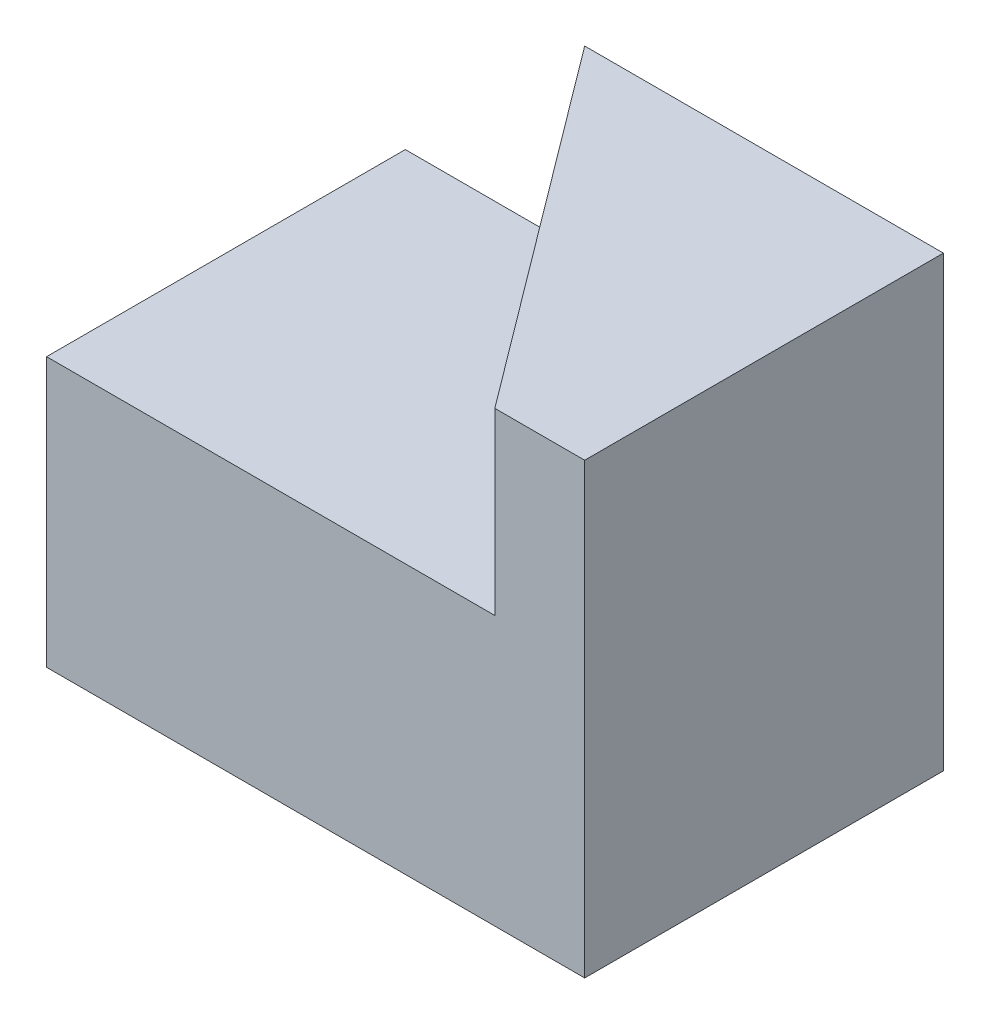
from build123d import *

# Parameters (mm, degrees)
SKETCH1_W           = 6
SKETCH1_H           = 4
BOSS_EXTRUDE1_DEPTH = 3
BOSS_EXTRUDE2_DEPTH = 2


with BuildPart() as part:
    # Sketch1 → Boss-Extrude1 (new body)
    with BuildSketch(Plane(origin=(0, 0, 0), x_dir=(1, 0, 0), z_dir=(0, 1, 0))):
        with Locations((3, 2)):
            Rectangle(SKETCH1_W, SKETCH1_H)
    extrude(amount=BOSS_EXTRUDE1_DEPTH)

    # Sketch3 → Boss-Extrude2 (add)
    with BuildSketch(Plane(origin=(0, 3, 0), x_dir=(1, 0, 0), z_dir=(0, 1, 0))):
        Polygon((6, 4), (6, 0), (4.997854063, 0), (2, 4), align=None)
    extrude(amount=BOSS_EXTRUDE2_DEPTH)


solid = part.part
